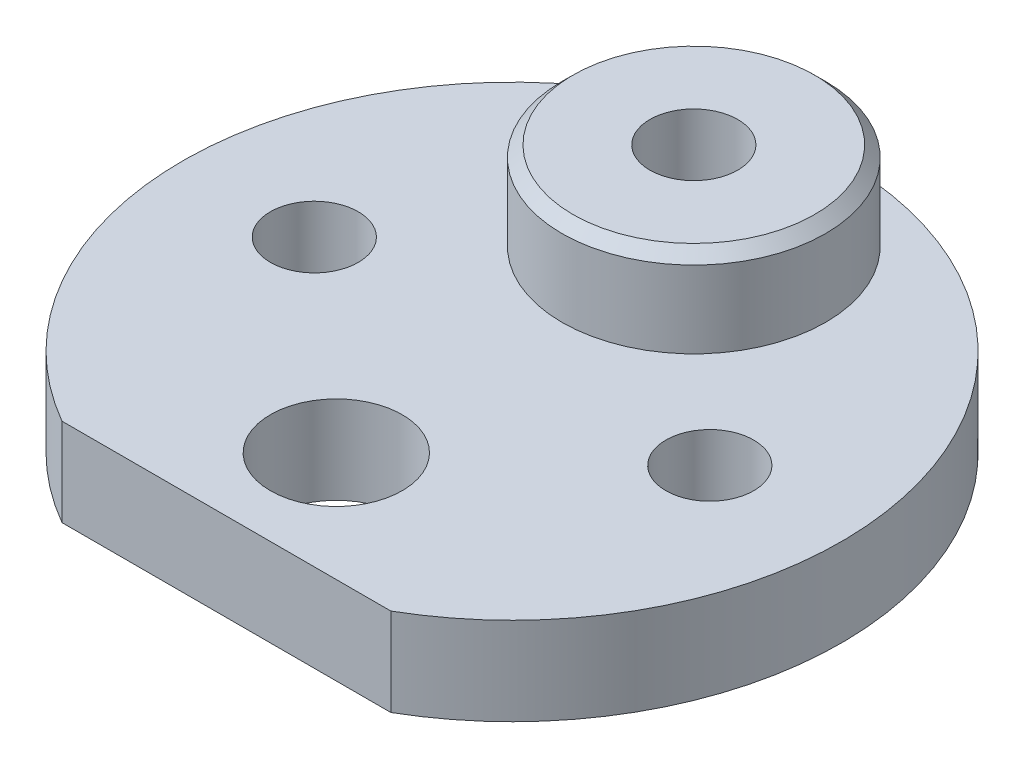
from build123d import *

# Parameters (mm, degrees)
SKETCH2_R           = 3
SKETCH2_R_2         = 2
BOSS_EXTRUDE1_DEPTH = 4
SKETCH3_R           = 6
BOSS_EXTRUDE2_DEPTH = 4
SKETCH4_R           = 2
CUT_EXTRUDE1_DEPTH  = 15
CHAMFER1_SIZE       = 0.5


with BuildPart() as part:
    # Sketch2 → Boss-Extrude1 (new body)
    with BuildSketch(Plane(origin=(0, 0, 0), x_dir=(1, 0, 0), z_dir=(0, 1, 0))):
        with BuildLine():
            Line((-7.483314774, -13), (7.483314774, -13))
            ThreePointArc((7.483314774, -13), (0, 15), (-7.483314774, -13))
        make_face()
        with Locations((0, -8)):
            Circle(SKETCH2_R, mode=Mode.SUBTRACT)
        with Locations((-9, 0)):
            Circle(SKETCH2_R_2, mode=Mode.SUBTRACT)
        with Locations((9, 0)):
            Circle(SKETCH2_R_2, mode=Mode.SUBTRACT)
    extrude(amount=BOSS_EXTRUDE1_DEPTH)

    # Sketch3 → Boss-Extrude2 (add)
    with BuildSketch(Plane(origin=(0, 4, 0), x_dir=(1, 0, 0), z_dir=(0, 1, 0))):
        with Locations((0, 8.272918614)):
            Circle(SKETCH3_R)
    extrude(amount=BOSS_EXTRUDE2_DEPTH)

    # Sketch4 → Cut-Extrude1 (cut)
    with BuildSketch(Plane(origin=(0, 8, 0), x_dir=(1, 0, 0), z_dir=(0, 1, 0))):
        with Locations((0, 8.272918614)):
            Circle(SKETCH4_R)
    extrude(amount=-CUT_EXTRUDE1_DEPTH, mode=Mode.SUBTRACT)

    # Chamfer1
    chamfer1_edges = [part.edges().sort_by_distance(p)[0] for p in [
        (-6, 8, -8.272918614),
    ]]
    chamfer(chamfer1_edges, length=CHAMFER1_SIZE)


solid = part.part
